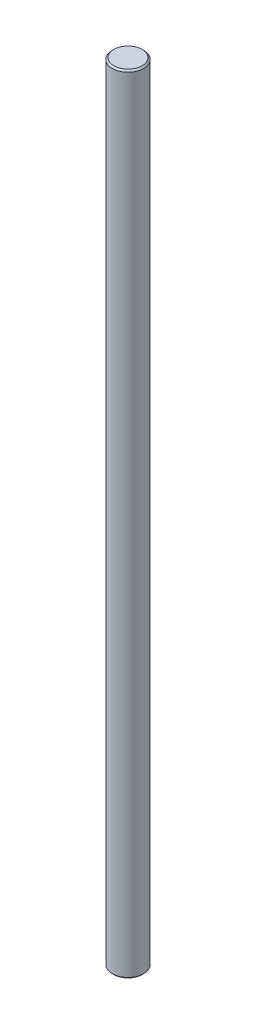
from build123d import *

# Parameters (mm, degrees)
SKETCH1_R           = 10
BOSS_EXTRUDE1_DEPTH = 500
CHAMFER1_SIZE       = 1


with BuildPart() as part:
    # Sketch1 → Boss-Extrude1 (new body)
    with BuildSketch(Plane(origin=(0, 0, 0), x_dir=(1, 0, 0), z_dir=(0, 1, 0))):
        Circle(SKETCH1_R)
    extrude(amount=BOSS_EXTRUDE1_DEPTH)

    # Chamfer1
    chamfer1_edges = [part.edges().sort_by_distance(p)[0] for p in [
        (-10, 0, 0),
        (-10, 500, 0),
    ]]
    chamfer(chamfer1_edges, length=CHAMFER1_SIZE)


solid = part.part
